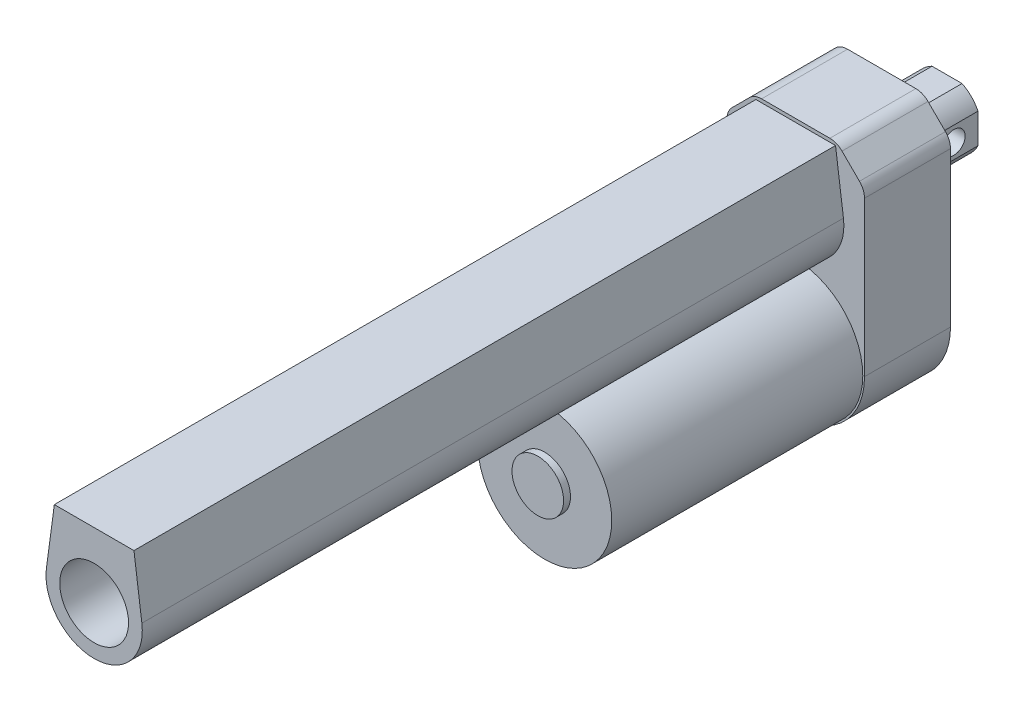
from build123d import *

# Parameters (mm, degrees)
EXTRUDE_1_DEPTH     = 25
SKETCH_2_R          = 19.5
EXTRUDE_2_DEPTH     = 73
SKETCH_3_R          = 7.5
EXTRUDE_3_DEPTH     = 2
EXTRUDE_4_DEPTH     = 204
SKETCH_5_R          = 10
CUT_EXTRUDE_1_DEPTH = 410
EXTRUDE_5_DEPTH     = 19
SKETCH_7_R          = 3.25
CUT_EXTRUDE_2_DEPTH = 20


with BuildPart() as part:
    # 草图1 → 凸台-拉伸1 (new body)
    with BuildSketch(Plane.XY):
        with BuildLine():
            Line((-20, 0), (-20, 44.928932188))
            ThreePointArc((-20, 44.928932188), (-19.619397663, 46.84234935), (-18.535533906, 48.464466094))
            Line((-18.535533906, 48.464466094), (-13.464466094, 53.535533906))
            ThreePointArc((-13.464466094, 53.535533906), (-11.84234935, 54.619397663), (-9.928932188, 55))
            Line((-9.928932188, 55), (9.928932188, 55))
            ThreePointArc((9.928932188, 55), (11.84234935, 54.619397663), (13.464466094, 53.535533906))
            Line((13.464466094, 53.535533906), (18.535533906, 48.464466094))
            ThreePointArc((18.535533906, 48.464466094), (19.619397663, 46.84234935), (20, 44.928932188))
            Line((20, 44.928932188), (20, 0))
            ThreePointArc((20, 0), (0, -20), (-20, 0))
        make_face()
    extrude(amount=EXTRUDE_1_DEPTH)

    # 草图2 → 凸台-拉伸2 (add)
    with BuildSketch(Plane.XY.offset(25)):
        Circle(SKETCH_2_R)
    extrude(amount=EXTRUDE_2_DEPTH)

    # 草图3 → 凸台-拉伸3 (add)
    with BuildSketch(Plane.XY.offset(98)):
        Circle(SKETCH_3_R)
    extrude(amount=EXTRUDE_3_DEPTH)

    # 草图4 → 凸台-拉伸4 (add)
    with BuildSketch(Plane.XY.offset(25)):
        with BuildLine():
            Line((-11.576521962, 54), (-13.87569737, 36.861457087))
            ThreePointArc((-13.87569737, 36.861457087), (0, 21), (13.87569737, 36.861457087))
            Line((13.87569737, 36.861457087), (11.576521962, 54))
            Line((11.576521962, 54), (-11.576521962, 54))
        make_face()
    extrude(amount=EXTRUDE_4_DEPTH)

    # 草图5 → 切除-拉伸1 (cut)
    with BuildSketch(Plane.XY.offset(229)):
        with Locations((0, 35)):
            Circle(SKETCH_5_R)
    extrude(amount=-CUT_EXTRUDE_1_DEPTH, mode=Mode.SUBTRACT)


with BuildPart() as body_2:
    # 草图6 → 凸台-拉伸5 (new body)
    with BuildSketch(Plane(origin=(0, 0, 0), x_dir=(-1, 0, 0), z_dir=(0, 0, -1))):
        with BuildLine():
            Line((-4.358898944, 44), (4.358898944, 44))
            ThreePointArc((4.358898944, 44), (7.071067812, 42.071067812), (9, 39.358898944))
            Line((9, 39.358898944), (9, 30.641101056))
            ThreePointArc((9, 30.641101056), (7.071067812, 27.928932188), (4.358898944, 26))
            Line((4.358898944, 26), (-4.358898944, 26))
            ThreePointArc((-4.358898944, 26), (-7.071067812, 27.928932188), (-9, 30.641101056))
            Line((-9, 30.641101056), (-9, 39.358898944))
            ThreePointArc((-9, 39.358898944), (-7.071067812, 42.071067812), (-4.358898944, 44))
        make_face()
    extrude(amount=EXTRUDE_5_DEPTH)

    # 草图7 → 切除-拉伸2 (cut)
    with BuildSketch(Plane(origin=(9, 0, 0), x_dir=(0, 0, -1), z_dir=(1, 0, 0))):
        with Locations((12, 35)):
            Circle(SKETCH_7_R)
    extrude(amount=-CUT_EXTRUDE_2_DEPTH, mode=Mode.SUBTRACT)


solid = Compound([part.part, body_2.part])
